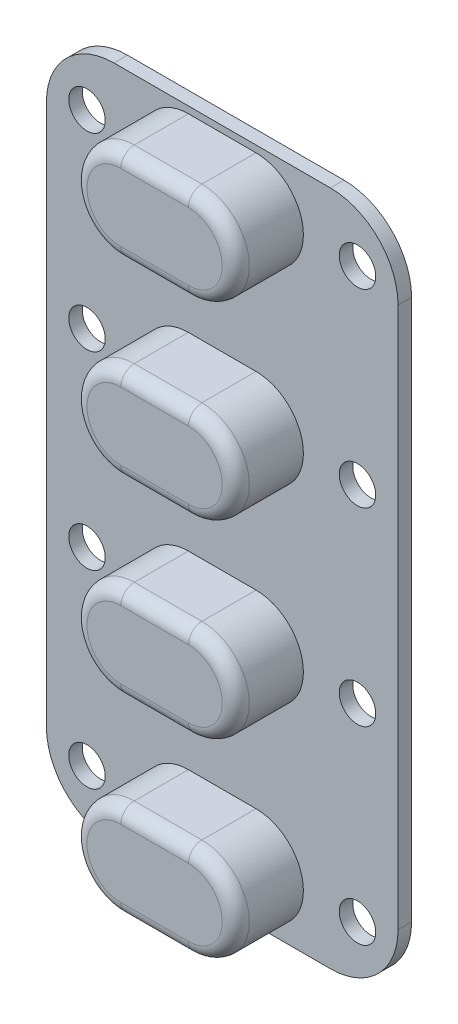
from build123d import *

# Parameters (mm, degrees)
SKETCH1_W           = 26
SKETCH1_H           = 50
SKETCH1_R           = 1.35
BOSS_EXTRUDE1_DEPTH = 1
BOSS_EXTRUDE2_DEPTH = 5
FILLET1_R           = 1
FILLET2_R           = 5
SKETCH3_R           = 2.625
CUT_EXTRUDE1_DEPTH  = 3


with BuildPart() as part:
    # Sketch1 → Boss-Extrude1 (new body)
    with BuildSketch(Plane.XY):
        Rectangle(SKETCH1_W, SKETCH1_H)
        with Locations((10, -21)):
            Circle(SKETCH1_R, mode=Mode.SUBTRACT)
        with Locations((10, -7)):
            Circle(SKETCH1_R, mode=Mode.SUBTRACT)
        with Locations((10, 7)):
            Circle(SKETCH1_R, mode=Mode.SUBTRACT)
        with Locations((10, 21)):
            Circle(SKETCH1_R, mode=Mode.SUBTRACT)
        with Locations((-10, -7)):
            Circle(SKETCH1_R, mode=Mode.SUBTRACT)
        with Locations((-10, 7)):
            Circle(SKETCH1_R, mode=Mode.SUBTRACT)
        with Locations((-10, 21)):
            Circle(SKETCH1_R, mode=Mode.SUBTRACT)
        with Locations((-10, -21)):
            Circle(SKETCH1_R, mode=Mode.SUBTRACT)
    extrude(amount=BOSS_EXTRUDE1_DEPTH)

    # Sketch2 → Boss-Extrude2 (add)
    with BuildSketch(Plane.XY.offset(1)):
        with BuildLine():
            Line((-2.5, 24.5), (2.5, 24.5))
            ThreePointArc((2.5, 24.5), (6, 21), (2.5, 17.5))
            Line((2.5, 17.5), (-2.5, 17.5))
            ThreePointArc((-2.5, 17.5), (-6, 21), (-2.5, 24.5))
        make_face()
        with BuildLine():
            Line((-2.5, 3.5), (2.5, 3.5))
            ThreePointArc((2.5, 3.5), (6, 7), (2.5, 10.5))
            Line((2.5, 10.5), (-2.5, 10.5))
            ThreePointArc((-2.5, 10.5), (-6, 7), (-2.5, 3.5))
        make_face()
        with BuildLine():
            Line((-2.5, -10.5), (2.5, -10.5))
            ThreePointArc((2.5, -10.5), (6, -7), (2.5, -3.5))
            Line((2.5, -3.5), (-2.5, -3.5))
            ThreePointArc((-2.5, -3.5), (-6, -7), (-2.5, -10.5))
        make_face()
        with BuildLine():
            Line((-2.5, -24.5), (2.5, -24.5))
            ThreePointArc((2.5, -24.5), (6, -21), (2.5, -17.5))
            Line((2.5, -17.5), (-2.5, -17.5))
            ThreePointArc((-2.5, -17.5), (-6, -21), (-2.5, -24.5))
        make_face()
    extrude(amount=BOSS_EXTRUDE2_DEPTH)

    # Fillet1
    fillet1_edges = [part.edges().sort_by_distance(p)[0] for p in [
        (-6, 21, 6),
        (0, 17.5, 6),
        (6, 21, 6),
        (0, 24.5, 6),
        (-6, 7, 6),
        (0, 3.5, 6),
        (6, 7, 6),
        (0, 10.5, 6),
        (-6, -7, 6),
        (0, -10.5, 6),
        (6, -7, 6),
        (0, -3.5, 6),
        (-6, -21, 6),
        (0, -24.5, 6),
        (6, -21, 6),
        (0, -17.5, 6),
    ]]
    fillet(fillet1_edges, radius=FILLET1_R)

    # Fillet2
    fillet2_edges = [part.edges().sort_by_distance(p)[0] for p in [
        (-13, 25, 0.5),
        (13, 25, 0.5),
        (13, -25, 0.5),
        (-13, -25, 0.5),
    ]]
    fillet(fillet2_edges, radius=FILLET2_R)

    # Sketch3 → Cut-Extrude1 (cut)
    with BuildSketch(Plane(origin=(0, 0, 0), x_dir=(-1, 0, 0), z_dir=(0, 0, -1))):
        with Locations((0, 21)):
            Circle(SKETCH3_R)
        with Locations((0, 7)):
            Circle(SKETCH3_R)
        with Locations((0, -7)):
            Circle(SKETCH3_R)
        with Locations((0, -21)):
            Circle(SKETCH3_R)
    extrude(amount=-CUT_EXTRUDE1_DEPTH, mode=Mode.SUBTRACT)


solid = part.part
